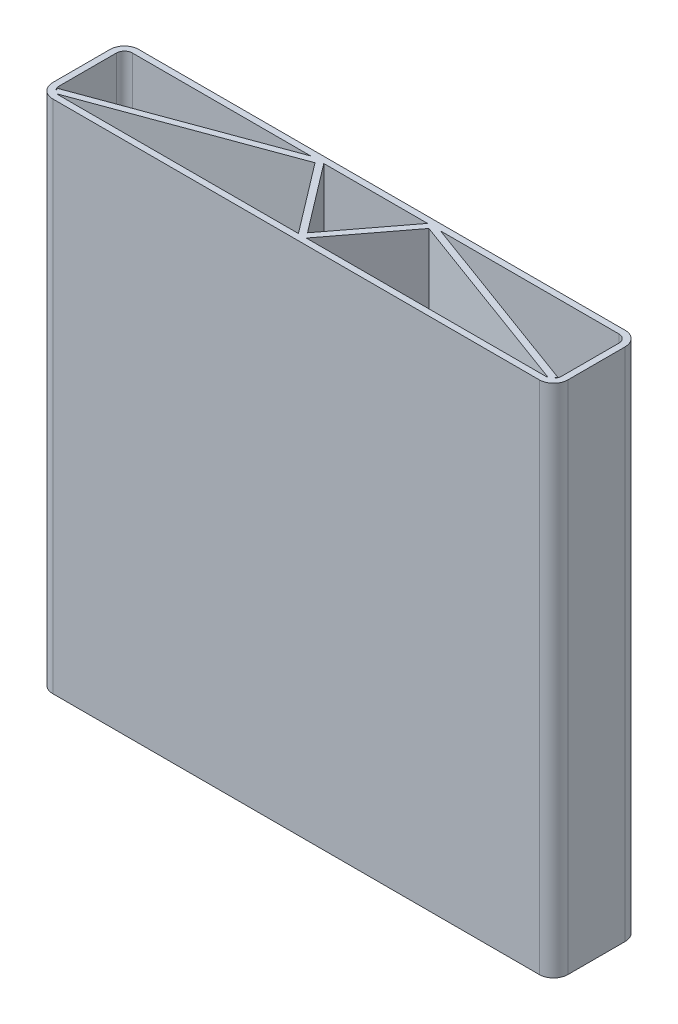
from build123d import *

# Parameters (mm, degrees)
EXTRUDE_THIN1_DEPTH = 1828.8
EXTRUDE_THIN3_DEPTH = 1828.8


with BuildPart() as part:
    # Sketch1 → Extrude-Thin1 (new body)
    with BuildSketch(Plane(origin=(0, 0, 0), x_dir=(1, 0, 0), z_dir=(0, 1, 0))):
        with BuildLine():
            Line((-863.6, 152.4), (863.6, 152.4))
            ThreePointArc((863.6, 152.4), (899.521024484, 137.521024484), (914.4, 101.6))
            Line((914.4, 101.6), (914.4, -101.6))
            ThreePointArc((914.4, -101.6), (899.521024484, -137.521024484), (863.6, -152.4))
            Line((863.6, -152.4), (-863.6, -152.4))
            ThreePointArc((-863.6, -152.4), (-899.521024484, -137.521024484), (-914.4, -101.6))
            Line((-914.4, -101.6), (-914.4, 101.6))
            ThreePointArc((-914.4, 101.6), (-899.521024484, 137.521024484), (-863.6, 152.4))
        make_face()
        with BuildLine():
            Line((-863.6, 130.175), (863.6, 130.175))
            ThreePointArc((863.6, 130.175), (883.805576272, 121.805576272), (892.175, 101.6))
            Line((892.175, 101.6), (892.175, -101.6))
            ThreePointArc((892.175, -101.6), (883.805576272, -121.805576272), (863.6, -130.175))
            Line((863.6, -130.175), (-863.6, -130.175))
            ThreePointArc((-863.6, -130.175), (-883.805576272, -121.805576272), (-892.175, -101.6))
            Line((-892.175, -101.6), (-892.175, 101.6))
            ThreePointArc((-892.175, 101.6), (-883.805576272, 121.805576272), (-863.6, 130.175))
        make_face(mode=Mode.SUBTRACT)
    extrude(amount=EXTRUDE_THIN1_DEPTH)

    # Sketch2 → Extrude-Thin3 (add)
    with BuildSketch(Plane(origin=(0, 1828.8, 0), x_dir=(1, 0, 0), z_dir=(0, 1, 0))):
        Polygon((-879.97255462, -132.236089264), (-201.982109296, 116.912927618), (0, -148.525916816), (201.982109296, 116.912927618), (879.97255462, -132.236089264), (887.638597925, -111.375063281), (194.237534197, 143.437072382), (0, -111.824083184), (-194.237534197, 143.437072382), (-887.638597925, -111.375063281), align=None)
    extrude(amount=-EXTRUDE_THIN3_DEPTH)


solid = part.part
